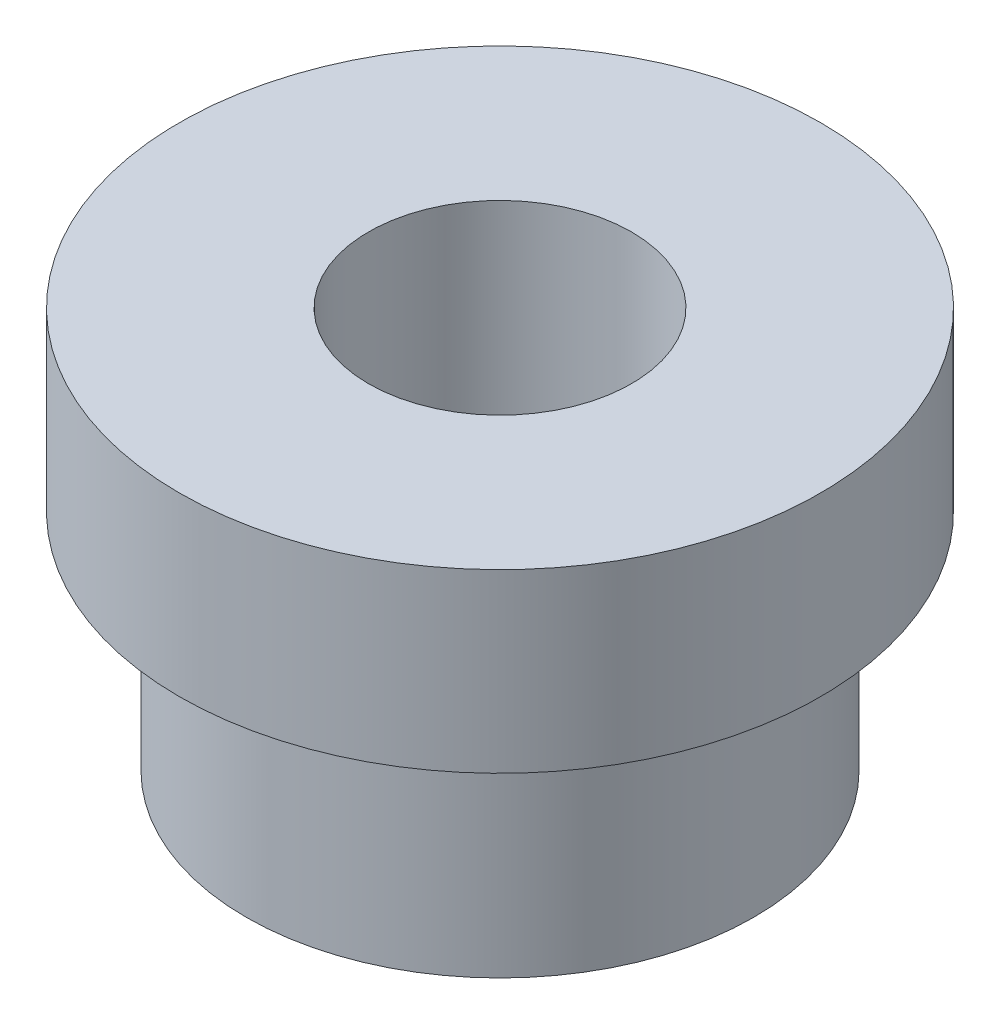
from build123d import *

# Parameters (mm, degrees)
M14X1_5_TAPPED_HOLE1_D = 12.5


with BuildPart() as part:
    # Sketch3 → Revolve1 (revolve)
    with BuildSketch(Plane.XY):
        Polygon((0, 19.05), (0, 0), (12.065, 0), (12.065, 10.668), (15.24, 10.668), (15.24, 19.05), align=None)
    revolve(axis=Axis((0, 17.78, 0), (0, 1, 0)))

    # M14x1.5 Tapped Hole1 (through all)
    with Locations(Plane(origin=(0, 19.05, 0), x_dir=(1, 0, 0), z_dir=(0, 1, 0))):
        with Locations((0, 0)):
            Hole(M14X1_5_TAPPED_HOLE1_D / 2)


solid = part.part
